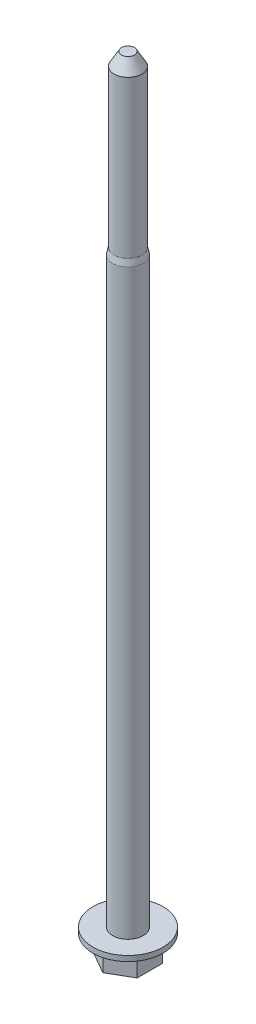
from build123d import *

# Parameters (mm, degrees)
BOSS_EXTRUDE1_DEPTH = 3.4
SKETCH2_R           = 5.48
BOSS_EXTRUDE2_DEPTH = 0.83
SKETCH3_R           = 2.385
BOSS_EXTRUDE3_DEPTH = 92
SKETCH4_R           = 2.165
BOSS_EXTRUDE4_DEPTH = 26.5
CHAMFER1_SIZE       = 2
CHAMFER1_SIZE2      = 1.154700538
CHAMFER2_SIZE       = 1
CHAMFER2_SIZE2      = 0.212556562


with BuildPart() as part:
    # Sketch1 → Boss-Extrude1 (new body)
    with BuildSketch(Plane(origin=(0, 0, 0), x_dir=(1, 0, 0), z_dir=(0, 1, 0))):
        Polygon((0, -3.937528836), (3.41, -1.968764418), (3.41, 1.968764418), (0, 3.937528836), (-3.41, 1.968764418), (-3.41, -1.968764418), align=None)
    extrude(amount=BOSS_EXTRUDE1_DEPTH)

    # Sketch2 → Boss-Extrude2 (add)
    with BuildSketch(Plane(origin=(0, 3.4, 0), x_dir=(1, 0, 0), z_dir=(0, 1, 0))):
        Circle(SKETCH2_R)
    extrude(amount=BOSS_EXTRUDE2_DEPTH)

    # Sketch3 → Boss-Extrude3 (add)
    with BuildSketch(Plane(origin=(0, 4.23, 0), x_dir=(1, 0, 0), z_dir=(0, 1, 0))):
        Circle(SKETCH3_R)
    extrude(amount=BOSS_EXTRUDE3_DEPTH)

    # Sketch4 → Boss-Extrude4 (add)
    with BuildSketch(Plane(origin=(0, 96.23, 0), x_dir=(1, 0, 0), z_dir=(0, 1, 0))):
        Circle(SKETCH4_R)
    extrude(amount=BOSS_EXTRUDE4_DEPTH)

    # Chamfer1
    chamfer1_edges = [part.edges().sort_by_distance(p)[0] for p in [
        (-2.165, 122.73, 0),
    ]]
    chamfer1_side = [part.faces().sort_by_distance(p)[0] for p in [
        (-2.165, 109.48, 0),
    ]]
    chamfer(chamfer1_edges, length=CHAMFER1_SIZE, length2=CHAMFER1_SIZE2, reference=chamfer1_side[0])

    # Chamfer2
    chamfer2_edges = [part.edges().sort_by_distance(p)[0] for p in [
        (-2.385, 96.23, 0),
    ]]
    chamfer2_side = [part.faces().sort_by_distance(p)[0] for p in [
        (-2.385, 50.23, 0),
    ]]
    chamfer(chamfer2_edges, length=CHAMFER2_SIZE, length2=CHAMFER2_SIZE2, reference=chamfer2_side[0])


solid = part.part
